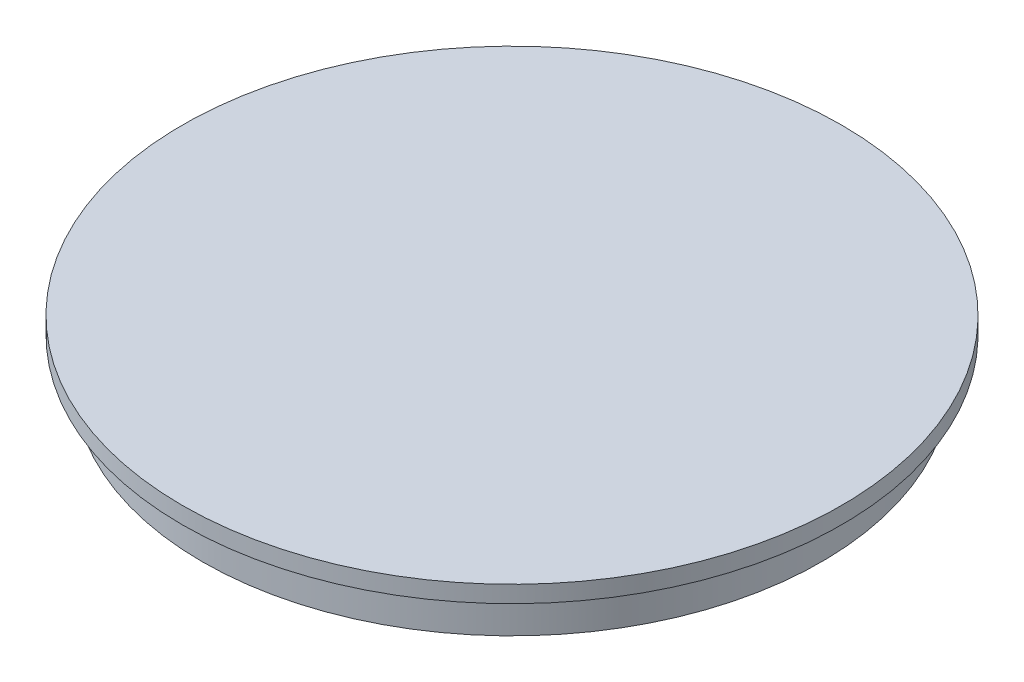
from build123d import *

# Parameters (mm, degrees)
SKETCH1_R           = 73.75
BOSS_EXTRUDE1_DEPTH = 10
SKETCH2_R           = 78.5
BOSS_EXTRUDE2_DEPTH = 4


with BuildPart() as part:
    # Sketch1 → Boss-Extrude1 (new body)
    with BuildSketch(Plane(origin=(0, 0, 0), x_dir=(1, 0, 0), z_dir=(0, 1, 0))):
        Circle(SKETCH1_R)
    extrude(amount=BOSS_EXTRUDE1_DEPTH)

    # Sketch2 → Boss-Extrude2 (add)
    with BuildSketch(Plane(origin=(0, 10, 0), x_dir=(1, 0, 0), z_dir=(0, 1, 0))):
        Circle(SKETCH2_R)
    extrude(amount=BOSS_EXTRUDE2_DEPTH)


solid = part.part
